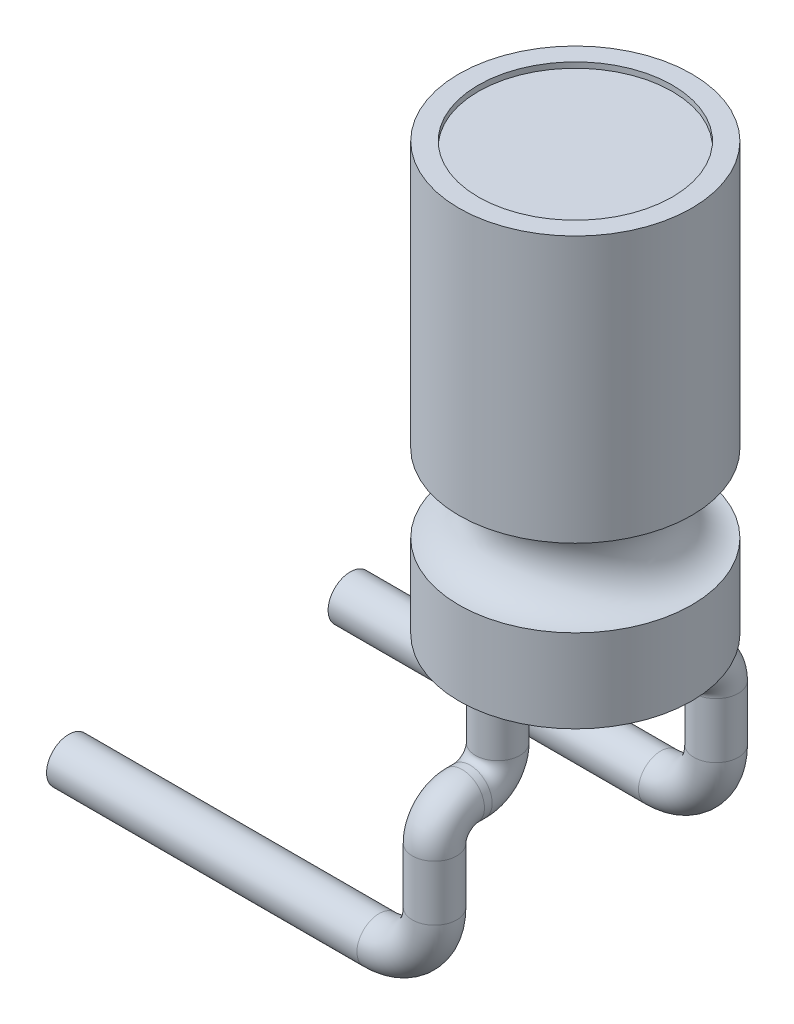
from build123d import *

# Parameters (mm, degrees)
ESQUISSE2_R             = 1.75
ENL_V_MAT_EXTRU_1_DEPTH = 0.1
ESQUISSE3_R             = 0.4
ESQUISSE5_R             = 0.4


with BuildPart() as part:
    # Esquisse1 → Révolution1 (revolve)
    with BuildSketch(Plane.XY, mode=Mode.PRIVATE) as r_volution1_sk:
        with BuildLine():
            Line((0, 35.216423663), (2.1, 35.216423663))
            Line((2.1, 35.216423663), (2.1, 30.416423663))
            ThreePointArc((2.1, 30.416423663), (1.4, 29.716423663), (2.1, 29.016423663))
            Line((2.1, 29.016423663), (2.1, 27.516423663))
            Line((2.1, 27.516423663), (0, 27.516423663))
            Line((0, 27.516423663), (0, 35.216423663))
        make_face()
    revolve(r_volution1_sk.sketch.rotate(Axis((0, 48.401709402, 0), (0, -1, 0)), 90), axis=Axis((0, 48.401709402, 0), (0, -1, 0)))  # turned: the seam where the file's is

    # Esquisse2 → Enlèv. mat.-Extru.1 (cut)
    with BuildSketch(Plane(origin=(0, 35.216423663, 0), x_dir=(-1, 0, 0), z_dir=(0, 1, 0))):
        with Locations(Location((0, 0, 0), (0, 0, 90))):  # turned: the seam where the file's is
            Circle(ESQUISSE2_R)
    extrude(amount=-ENL_V_MAT_EXTRU_1_DEPTH, mode=Mode.SUBTRACT)

    # Balayage1: sweep along a path in Esquisse4
    with BuildLine(Plane(origin=(0, 0, 0), x_dir=(0, 0, -1), z_dir=(1, 0, 0))) as balayage1_path:
        Line((-1.4, 27.516423663), (-1.4, 26.516423663))
        ThreePointArc((-1.4, 26.516423663), (-1.546446609, 26.162870273), (-1.9, 26.016423663))
        Line((-1.9, 26.016423663), (-2.04, 26.016423663))
        ThreePointArc((-2.04, 26.016423663), (-2.393553391, 25.869977054), (-2.54, 25.516423663))
    # Esquisse3 → Balayage1 (sweep)
    with BuildSketch(Plane.XZ.offset(-27.516423663)):
        with Locations((0, 1.4)):
            Circle(ESQUISSE3_R)
    balayage1 = sweep(path=balayage1_path.line)

    # Balayage2: sweep along a path in Esquisse6
    with BuildLine(Plane.XY.offset(2.54)) as balayage2_path:
        Line((0, 25.516423663), (0, 24.516423663))
        ThreePointArc((0, 24.516423663), (-0.292893219, 23.809316882), (-1, 23.516423663))
        Line((-1, 23.516423663), (-6.6, 23.516423663))
    # Esquisse5 → Balayage2 (sweep)
    with BuildSketch(Plane.XZ.offset(-25.516423663)):
        with Locations((0, 2.54)):
            Circle(ESQUISSE5_R)
    balayage2 = sweep(path=balayage2_path.line)

    # Symétrie1: Balayage1, Balayage2 across plane
    add(balayage1.mirror(Plane.XY))
    add(balayage2.mirror(Plane.XY))


solid = part.part
